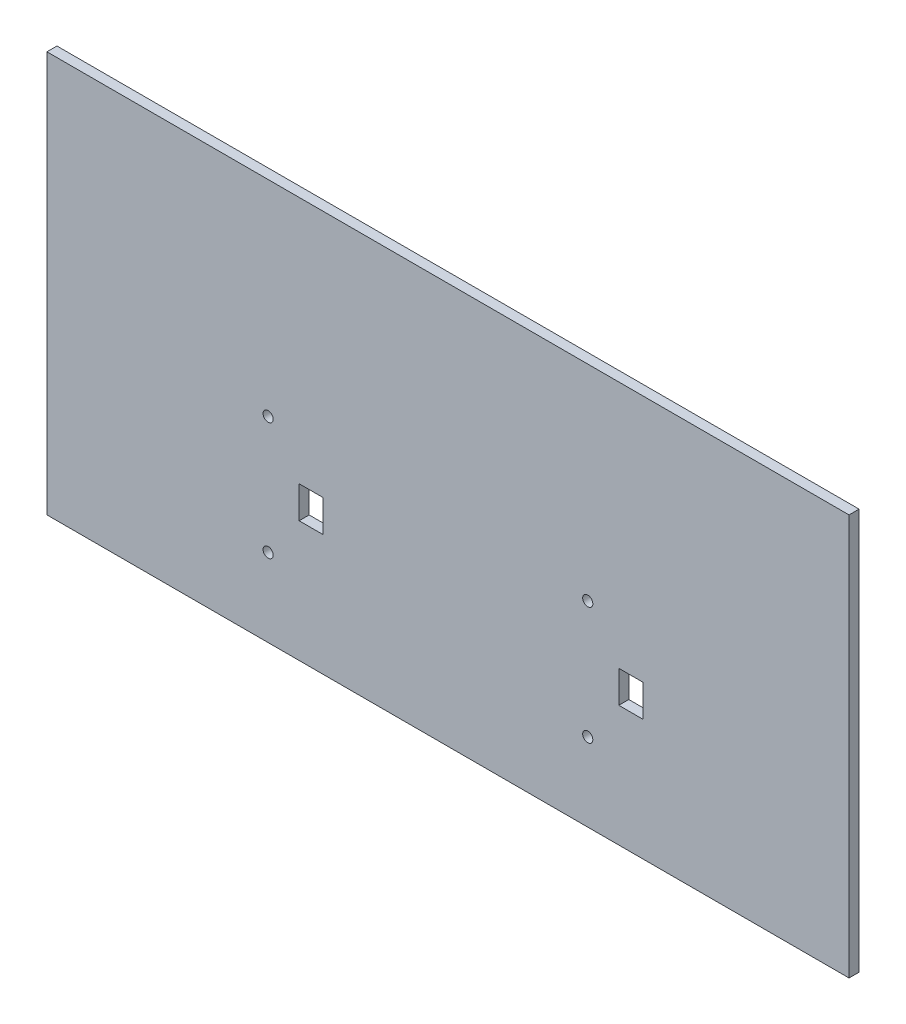
from build123d import *

# Parameters (mm, degrees)
SKETCH1_W           = 254
SKETCH1_H           = 127
BOSS_EXTRUDE1_DEPTH = 1.5875
SKETCH2_R           = 1.61
SKETCH2_W           = 7.62
SKETCH2_H           = 10.15
CUT_EXTRUDE1_DEPTH  = 5.08


with BuildPart() as part:
    # Sketch1 → Boss-Extrude1 (new body, symmetric)
    with BuildSketch(Plane.XY):
        Rectangle(SKETCH1_W, SKETCH1_H)
    extrude(amount=BOSS_EXTRUDE1_DEPTH, both=True)

    # Sketch2 → Cut-Extrude1 (cut)
    with BuildSketch(Plane.XY.offset(1.5875)):
        with Locations((-56.955000009, -1.46)):
            Circle(SKETCH2_R)
        with Locations((-56.955000009, -38.74)):
            Circle(SKETCH2_R)
        with Locations((44.25500001, -38.74)):
            Circle(SKETCH2_R)
        with Locations((44.25500001, -1.46)):
            Circle(SKETCH2_R)
        with Locations((-43.320000018, -20.1)):
            Rectangle(SKETCH2_W, SKETCH2_H)
        with Locations((57.890000001, -20.1)):
            Rectangle(SKETCH2_W, SKETCH2_H)
    extrude(amount=-CUT_EXTRUDE1_DEPTH, mode=Mode.SUBTRACT)


solid = part.part
